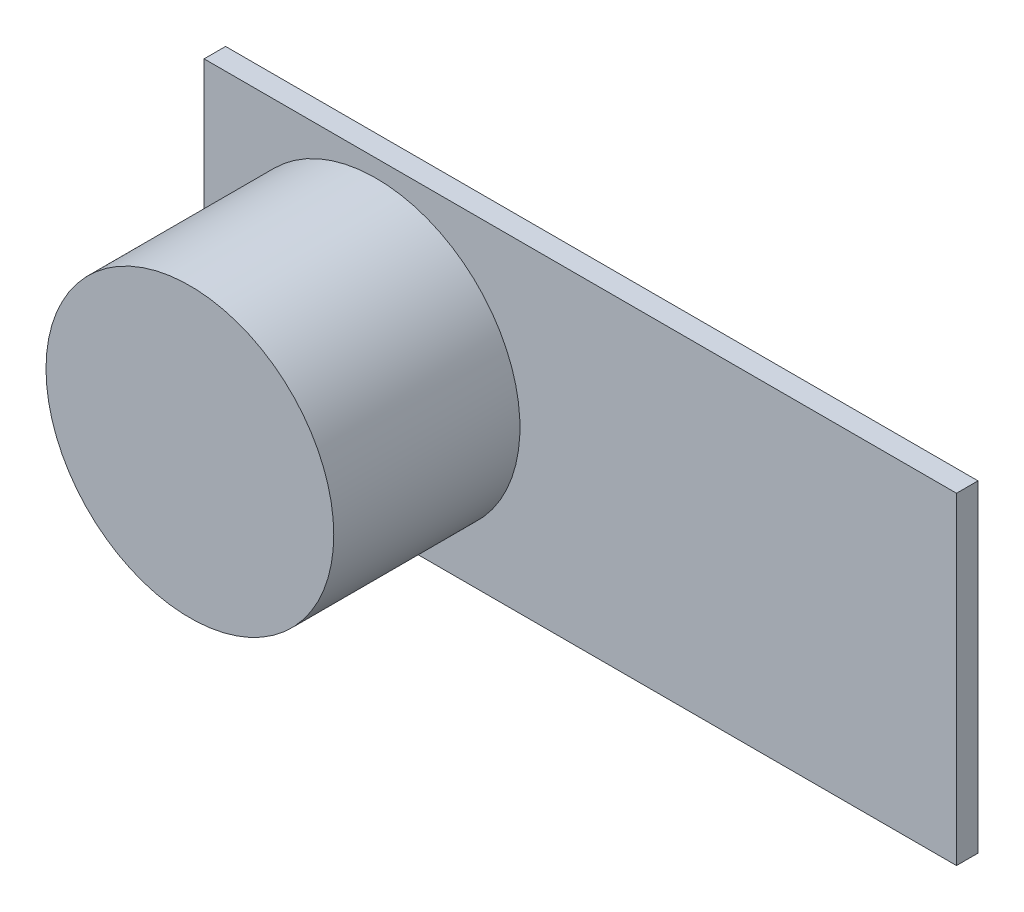
from build123d import *

# Parameters (mm, degrees)
SKETCH1_W           = 44.45
SKETCH1_H           = 19.05
BOSS_EXTRUDE1_DEPTH = 1.27
SKETCH2_R           = 8.5
BOSS_EXTRUDE2_DEPTH = 11


with BuildPart() as part:
    # Sketch1 → Boss-Extrude1 (new body)
    with BuildSketch(Plane.XY):
        with Locations((22.225, 9.525)):
            Rectangle(SKETCH1_W, SKETCH1_H)
    extrude(amount=BOSS_EXTRUDE1_DEPTH)

    # Sketch2 → Boss-Extrude2 (add)
    with BuildSketch(Plane.XY.offset(1.27)):
        with Locations((10.16, 9.525)):
            Circle(SKETCH2_R)
    extrude(amount=BOSS_EXTRUDE2_DEPTH)


solid = part.part
